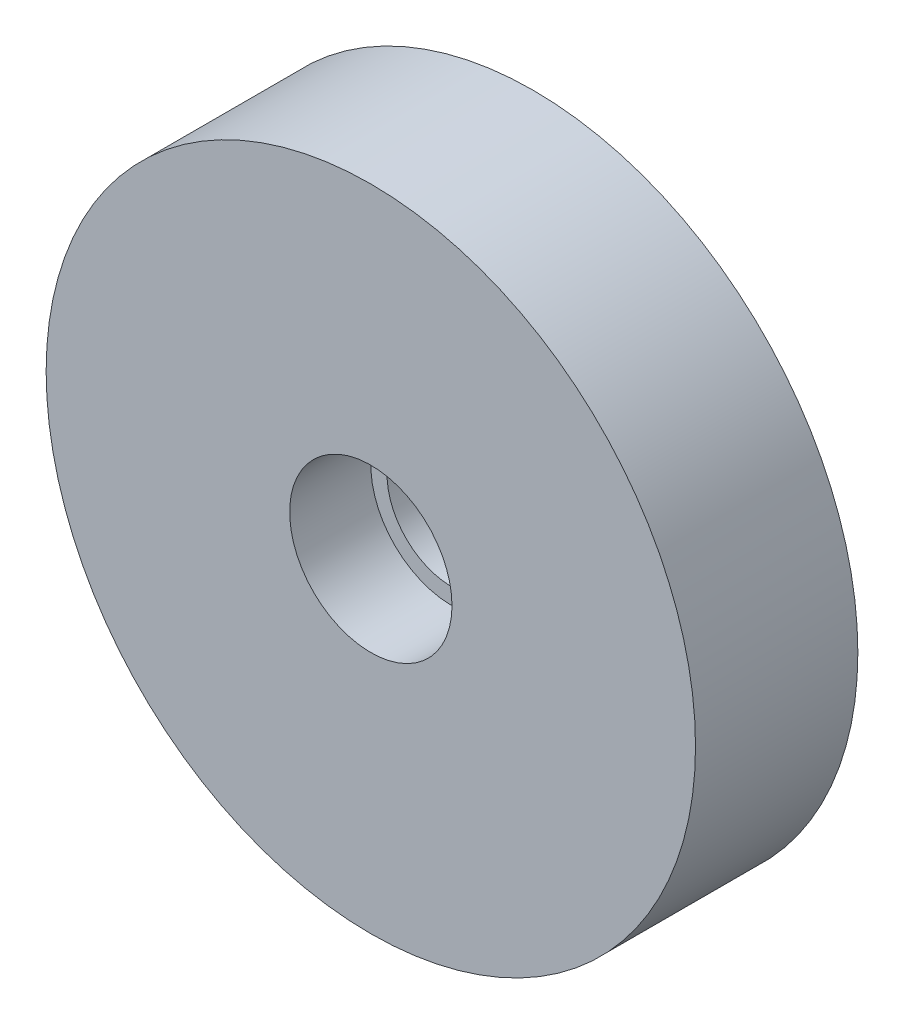
from build123d import *

# Parameters (mm, degrees)
ESQUISSE1_R             = 20
BOSS_EXTRU_1_DEPTH      = 10
ESQUISSE2_R             = 4
ENL_V_MAT_EXTRU_1_DEPTH = 11
ESQUISSE3_R             = 5
ENL_V_MAT_EXTRU_2_DEPTH = 5
ESQUISSE4_R             = 12
BOSS_EXTRU_2_DEPTH      = 5
ESQUISSE5_R             = 4
ENL_V_MAT_EXTRU_6_DEPTH = 16


with BuildPart() as part:
    # Esquisse1 → Boss.-Extru.1 (new body)
    with BuildSketch(Plane.XY):
        with Locations((0, 280)):
            Circle(ESQUISSE1_R)
    extrude(amount=BOSS_EXTRU_1_DEPTH)

    # Esquisse2 → Enlèv. mat.-Extru.1 (cut, through all)
    with BuildSketch(Plane.XY.offset(10)):
        with Locations((0, 280)):
            Circle(ESQUISSE2_R)
    extrude(amount=-ENL_V_MAT_EXTRU_1_DEPTH, mode=Mode.SUBTRACT)

    # Esquisse3 → Enlèv. mat.-Extru.2 (cut)
    with BuildSketch(Plane.XY.offset(10)):
        with Locations((0, 280)):
            Circle(ESQUISSE3_R)
    extrude(amount=-ENL_V_MAT_EXTRU_2_DEPTH, mode=Mode.SUBTRACT)

    # Esquisse4 → Boss.-Extru.2 (add)
    with BuildSketch(Plane(origin=(0, 0, 0), x_dir=(-1, 0, 0), z_dir=(0, 0, -1))):
        with Locations(Location((0, 280, 0), (0, 0, 180))):  # turned: the seam where the file's is
            Circle(ESQUISSE4_R)
    extrude(amount=BOSS_EXTRU_2_DEPTH)

    # Esquisse5 → Enlèv. mat.-Extru.6 (cut, through all)
    with BuildSketch(Plane(origin=(0, 0, -5), x_dir=(-1, 0, 0), z_dir=(0, 0, -1))):
        with Locations(Location((0, 280, 0), (0, 0, 180))):  # turned: the seam where the file's is
            Circle(ESQUISSE5_R)
    extrude(amount=-ENL_V_MAT_EXTRU_6_DEPTH, mode=Mode.SUBTRACT)


solid = part.part
